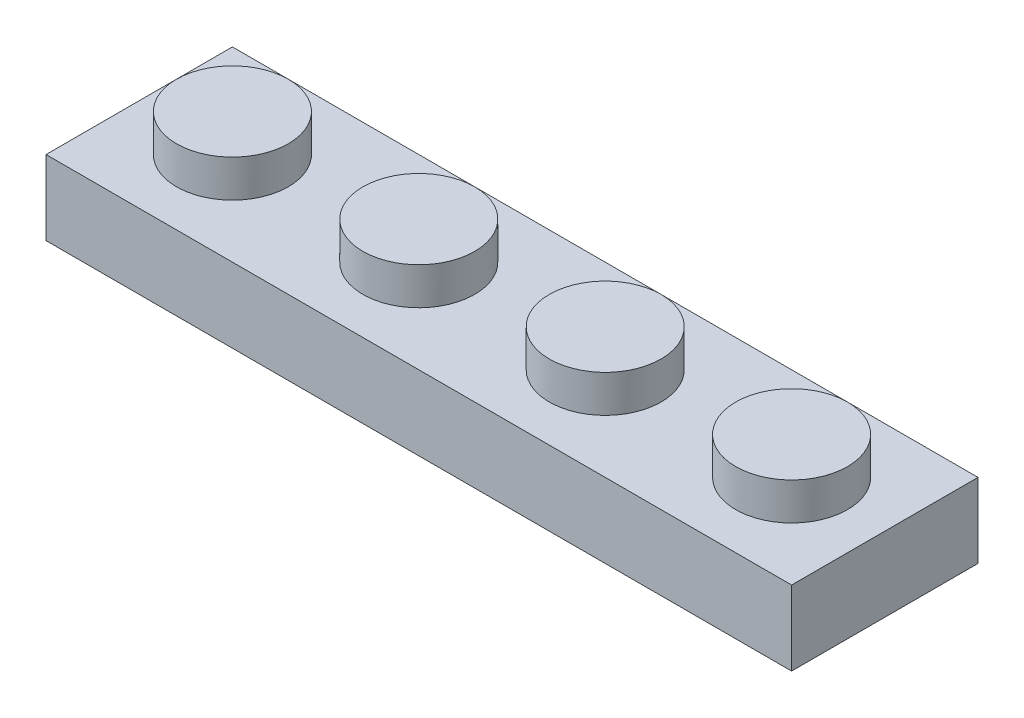
from build123d import *

# Parameters (mm, degrees)
SKETCH1_W           = 31.75
SKETCH1_H           = 7.9375
BOSS_EXTRUDE1_DEPTH = 3.175
SKETCH2_R           = 2.38125
BOSS_EXTRUDE2_DEPTH = 1.5875
SHELL1_T            = -1.5875
SKETCH3_R           = 1.5875
SKETCH3_R_2         = 0.79375
BOSS_EXTRUDE4_DEPTH = 1.397


with BuildPart() as part:
    # Sketch1 → Boss-Extrude1 (new body)
    with BuildSketch(Plane(origin=(0, 0, 0), x_dir=(1, 0, 0), z_dir=(0, 1, 0))):
        with Locations((15.875, 3.96875)):
            Rectangle(SKETCH1_W, SKETCH1_H)
    extrude(amount=BOSS_EXTRUDE1_DEPTH)

    # Sketch2 → Boss-Extrude2 (add)
    with BuildSketch(Plane(origin=(0, 3.175, 0), x_dir=(1, 0, 0), z_dir=(0, 1, 0))):
        with Locations((3.96875, 3.96875)):
            Circle(SKETCH2_R)
        with Locations((11.90625, 3.96875)):
            Circle(SKETCH2_R)
        with Locations((19.84375, 3.96875)):
            Circle(SKETCH2_R)
        with Locations((27.78125, 3.96875)):
            Circle(SKETCH2_R)
    extrude(amount=BOSS_EXTRUDE2_DEPTH)

    # Shell1
    shell1_openings = [part.faces().sort_by_distance(p)[0] for p in [
        (15.875, 0, -3.96875),
    ]]
    offset(amount=SHELL1_T, openings=shell1_openings, kind=Kind.INTERSECTION)

    # Sketch3 → Boss-Extrude4 (add)
    with BuildSketch(Plane.XZ.offset(-1.5875)):
        with Locations((7.540625, -3.96875)):
            Circle(SKETCH3_R)
        with Locations((7.540625, -3.96875)):
            Circle(SKETCH3_R_2, mode=Mode.SUBTRACT)
        with Locations((15.478125, -3.96875)):
            Circle(SKETCH3_R)
        with Locations((15.478125, -3.96875)):
            Circle(SKETCH3_R_2, mode=Mode.SUBTRACT)
        with Locations((23.415625, -3.96875)):
            Circle(SKETCH3_R)
        with Locations((23.415625, -3.96875)):
            Circle(SKETCH3_R_2, mode=Mode.SUBTRACT)
    extrude(amount=BOSS_EXTRUDE4_DEPTH)


solid = part.part
